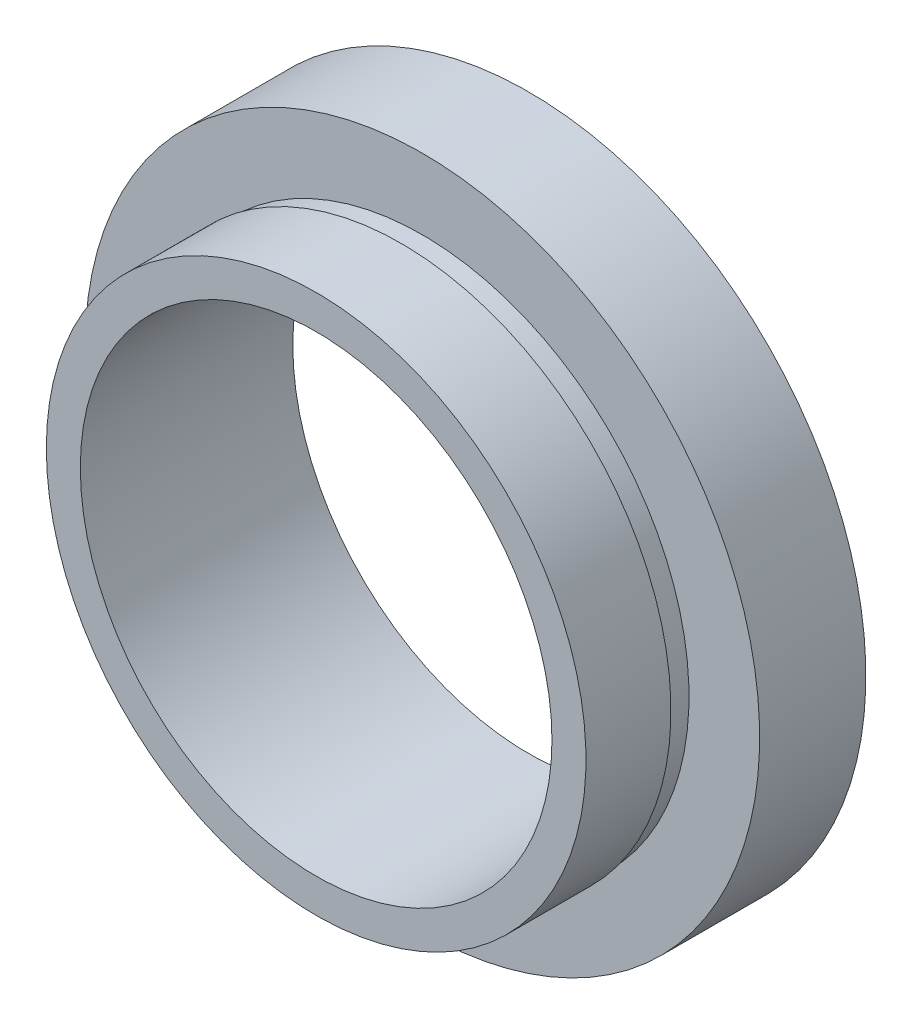
from build123d import *


with BuildPart() as part:
    # 草图1 → 旋转1 (revolve)
    with BuildSketch(Plane(origin=(0, 0, 0), x_dir=(1, 0, 0), z_dir=(0, 1, 0)), mode=Mode.PRIVATE) as revolve_1_sk:
        Polygon((11.1, 0), (11.1, 10), (15.875, 10), (15.875, 5), (12.55, 5), (12.55, 4), (12.7, 4), (12.7, 0), align=None)
    revolve(revolve_1_sk.sketch.rotate(Axis((0, 0, -19.14057971), (0, 0, 1)), 180), axis=Axis((0, 0, -19.14057971), (0, 0, 1)))  # turned: the seam where the file's is


solid = part.part
